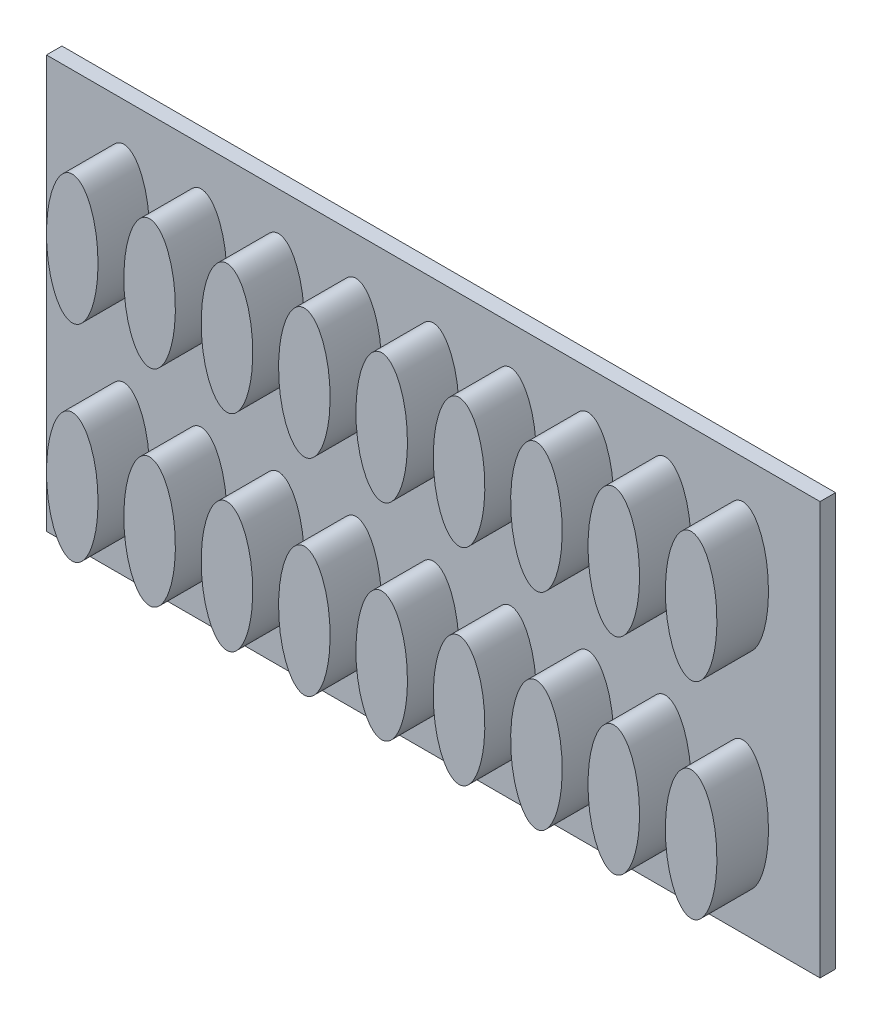
from build123d import *

# Parameters (mm, degrees)
SKICA1_W            = 150
SKICA1_H            = 80
VYSUNOUT1_DEPTH     = 3
SKICA2_RX           = 12.5
SKICA2_RY           = 5
VYSUNOUT2_DEPTH     = 10
LINPOLE1_COUNT      = 9
LINPOLE1_PITCH      = 15
LINPOLE1_COUNT_DIR2 = 2
LINPOLE1_PITCH_DIR2 = 40


with BuildPart() as part:
    # Skica1 → Vysunout1 (new body)
    with BuildSketch(Plane.XY):
        with Locations((75, 40)):
            Rectangle(SKICA1_W, SKICA1_H)
    extrude(amount=VYSUNOUT1_DEPTH)

    # Skica2 → Vysunout2 (add)
    with BuildSketch(Plane.XY.offset(3)):
        with Locations(Location((15, 60), (0, 0, 90))):
            Ellipse(SKICA2_RX, SKICA2_RY)
    vysunout2 = extrude(amount=VYSUNOUT2_DEPTH)

    # LinPole1: Vysunout2 9 × 2
    with Locations(*[(i * LINPOLE1_PITCH, -j * LINPOLE1_PITCH_DIR2, 0) for i in range(LINPOLE1_COUNT) for j in range(LINPOLE1_COUNT_DIR2) if (i, j) != (0, 0)]):
        add(vysunout2)


solid = part.part
